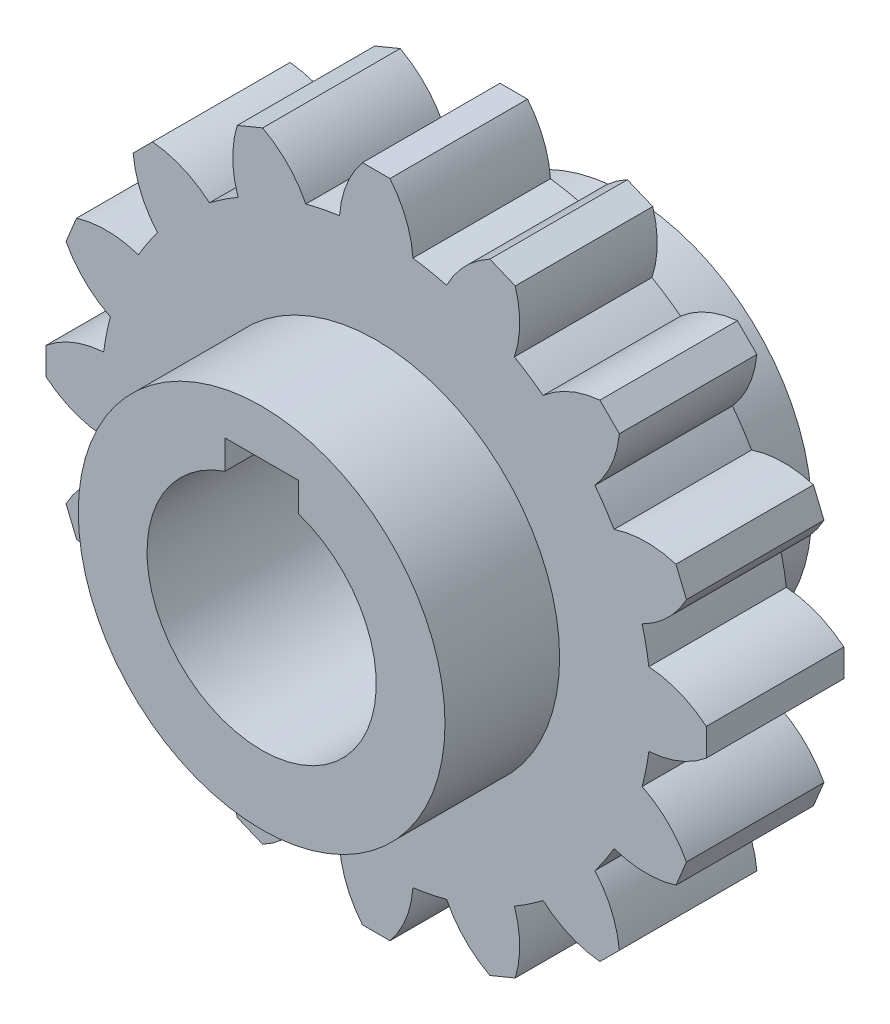
from build123d import *

# Parameters (mm, degrees)
BOSS_EXTRUDE1_DEPTH = 7.5
SKETCH2_R           = 20
BOSS_EXTRUDE2_DEPTH = 20
CUT_EXTRUDE1_DEPTH  = 41


with BuildPart() as part:
    # Sketch1 → Boss-Extrude1 (new body, symmetric)
    with BuildSketch(Plane.XY):
        with BuildLine():
            Line((-1.5, 36), (1.5, 36))
            ThreePointArc((1.5, 36), (3.242504384, 33.062509074), (4, 29.732137495))
            ThreePointArc((4, 29.732137495), (5.85270966, 29.423558412), (7.682478298, 28.999647019))
            ThreePointArc((7.682478298, 28.999647019), (9.656791021, 31.786628134), (12.390784266, 33.833688319))
            Line((12.390784266, 33.833688319), (15.162422864, 32.685638022))
            ThreePointArc((15.162422864, 32.685638022), (15.64815789, 29.30492272), (15.073514558, 25.93817956))
            ThreePointArc((15.073514558, 25.93817956), (16.667106991, 24.944088369), (18.195368917, 23.852223166))
            ThreePointArc((18.195368917, 23.852223166), (21.085927531, 25.671521208), (24.395183951, 26.516504294))
            Line((24.395183951, 26.516504294), (26.516504294, 24.395183951))
            ThreePointArc((26.516504294, 24.395183951), (25.671521208, 21.085927531), (23.852223166, 18.195368917))
            ThreePointArc((23.852223166, 18.195368917), (24.944088369, 16.667106991), (25.93817956, 15.073514558))
            ThreePointArc((25.93817956, 15.073514558), (29.30492272, 15.64815789), (32.685638022, 15.162422864))
            Line((32.685638022, 15.162422864), (33.833688319, 12.390784266))
            ThreePointArc((33.833688319, 12.390784266), (31.786628134, 9.656791021), (28.999647019, 7.682478298))
            ThreePointArc((28.999647019, 7.682478298), (29.423558412, 5.85270966), (29.732137495, 4))
            ThreePointArc((29.732137495, 4), (33.062509074, 3.242504384), (36, 1.5))
            Line((36, 1.5), (36, -1.5))
            ThreePointArc((36, -1.5), (33.062509074, -3.242504384), (29.732137495, -4))
            ThreePointArc((29.732137495, -4), (29.423558412, -5.85270966), (28.999647019, -7.682478298))
            ThreePointArc((28.999647019, -7.682478298), (31.786628134, -9.656791021), (33.833688319, -12.390784266))
            Line((33.833688319, -12.390784266), (32.685638022, -15.162422864))
            ThreePointArc((32.685638022, -15.162422864), (29.30492272, -15.64815789), (25.93817956, -15.073514558))
            ThreePointArc((25.93817956, -15.073514558), (24.944088369, -16.667106991), (23.852223166, -18.195368917))
            ThreePointArc((23.852223166, -18.195368917), (25.671521208, -21.085927531), (26.516504294, -24.395183951))
            Line((26.516504294, -24.395183951), (24.395183951, -26.516504294))
            ThreePointArc((24.395183951, -26.516504294), (21.085927531, -25.671521208), (18.195368917, -23.852223166))
            ThreePointArc((18.195368917, -23.852223166), (16.667106991, -24.944088369), (15.073514558, -25.93817956))
            ThreePointArc((15.073514558, -25.93817956), (15.64815789, -29.30492272), (15.162422864, -32.685638022))
            Line((15.162422864, -32.685638022), (12.390784266, -33.833688319))
            ThreePointArc((12.390784266, -33.833688319), (9.656791021, -31.786628134), (7.682478298, -28.999647019))
            ThreePointArc((7.682478298, -28.999647019), (5.85270966, -29.423558412), (4, -29.732137495))
            ThreePointArc((4, -29.732137495), (3.242504384, -33.062509074), (1.5, -36))
            Line((1.5, -36), (-1.5, -36))
            ThreePointArc((-1.5, -36), (-3.242504384, -33.062509074), (-4, -29.732137495))
            ThreePointArc((-4, -29.732137495), (-5.85270966, -29.423558412), (-7.682478298, -28.999647019))
            ThreePointArc((-7.682478298, -28.999647019), (-9.656791021, -31.786628134), (-12.390784266, -33.833688319))
            Line((-12.390784266, -33.833688319), (-15.162422864, -32.685638022))
            ThreePointArc((-15.162422864, -32.685638022), (-15.64815789, -29.30492272), (-15.073514558, -25.93817956))
            ThreePointArc((-15.073514558, -25.93817956), (-16.667106991, -24.944088369), (-18.195368917, -23.852223166))
            ThreePointArc((-18.195368917, -23.852223166), (-21.085927531, -25.671521208), (-24.395183951, -26.516504294))
            Line((-24.395183951, -26.516504294), (-26.516504294, -24.395183951))
            ThreePointArc((-26.516504294, -24.395183951), (-25.671521208, -21.085927531), (-23.852223166, -18.195368917))
            ThreePointArc((-23.852223166, -18.195368917), (-24.944088369, -16.667106991), (-25.93817956, -15.073514558))
            ThreePointArc((-25.93817956, -15.073514558), (-29.30492272, -15.64815789), (-32.685638022, -15.162422864))
            Line((-32.685638022, -15.162422864), (-33.833688319, -12.390784266))
            ThreePointArc((-33.833688319, -12.390784266), (-31.786628134, -9.656791021), (-28.999647019, -7.682478298))
            ThreePointArc((-28.999647019, -7.682478298), (-29.423558412, -5.85270966), (-29.732137495, -4))
            ThreePointArc((-29.732137495, -4), (-33.062509074, -3.242504384), (-36, -1.5))
            Line((-36, -1.5), (-36, 1.5))
            ThreePointArc((-36, 1.5), (-33.062509074, 3.242504384), (-29.732137495, 4))
            ThreePointArc((-29.732137495, 4), (-29.423558412, 5.85270966), (-28.999647019, 7.682478298))
            ThreePointArc((-28.999647019, 7.682478298), (-31.786628134, 9.656791021), (-33.833688319, 12.390784266))
            Line((-33.833688319, 12.390784266), (-32.685638022, 15.162422864))
            ThreePointArc((-32.685638022, 15.162422864), (-29.30492272, 15.64815789), (-25.93817956, 15.073514558))
            ThreePointArc((-25.93817956, 15.073514558), (-24.944088369, 16.667106991), (-23.852223166, 18.195368917))
            ThreePointArc((-23.852223166, 18.195368917), (-25.671521208, 21.085927531), (-26.516504294, 24.395183951))
            Line((-26.516504294, 24.395183951), (-24.395183951, 26.516504294))
            ThreePointArc((-24.395183951, 26.516504294), (-21.085927531, 25.671521208), (-18.195368917, 23.852223166))
            ThreePointArc((-18.195368917, 23.852223166), (-16.667106991, 24.944088369), (-15.073514558, 25.93817956))
            ThreePointArc((-15.073514558, 25.93817956), (-15.64815789, 29.30492272), (-15.162422864, 32.685638022))
            Line((-15.162422864, 32.685638022), (-12.390784266, 33.833688319))
            ThreePointArc((-12.390784266, 33.833688319), (-9.656791021, 31.786628134), (-7.682478298, 28.999647019))
            ThreePointArc((-7.682478298, 28.999647019), (-5.85270966, 29.423558412), (-4, 29.732137495))
            ThreePointArc((-4, 29.732137495), (-3.242504384, 33.062509074), (-1.5, 36))
        make_face()
    extrude(amount=BOSS_EXTRUDE1_DEPTH, both=True)

    # Sketch2 → Boss-Extrude2 (add, symmetric)
    with BuildSketch(Plane.XY):
        Circle(SKETCH2_R)
    extrude(amount=BOSS_EXTRUDE2_DEPTH, both=True)

    # Sketch3 → Cut-Extrude1 (cut, through all)
    with BuildSketch(Plane.XY.offset(20)):
        with BuildLine():
            Line((-4, 15), (-4, 11.842719282))
            ThreePointArc((-4, 11.842719282), (0, -12.5), (4, 11.842719282))
            Line((4, 11.842719282), (4, 15))
            Line((4, 15), (-4, 15))
        make_face()
    extrude(amount=-CUT_EXTRUDE1_DEPTH, mode=Mode.SUBTRACT)


solid = part.part
